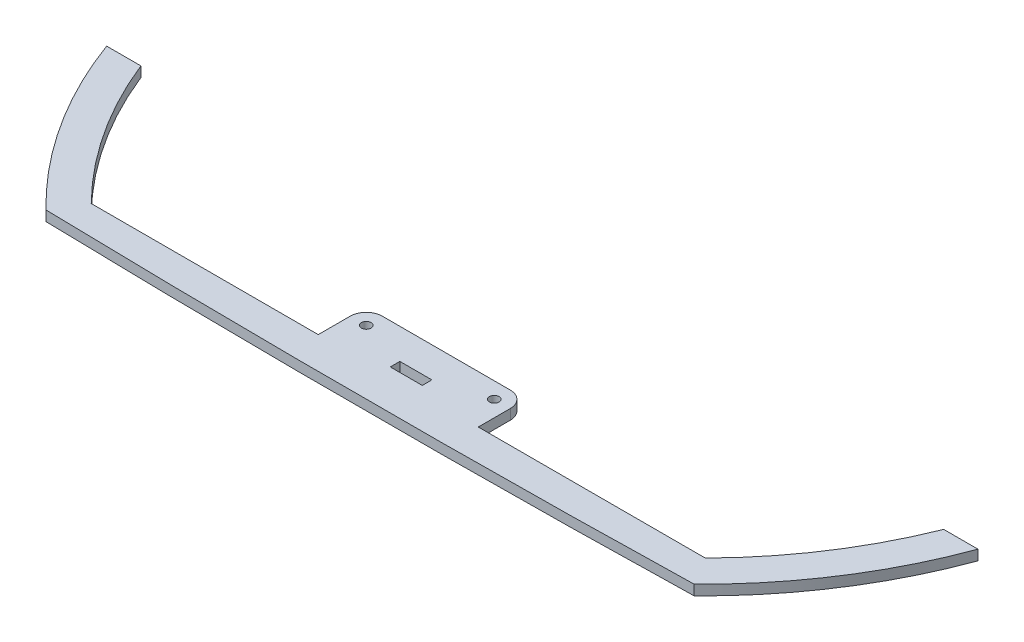
from build123d import *

# Parameters (mm, degrees)
SKETCH_1_R      = 1.5
SKETCH_1_W      = 10
SKETCH_1_H      = 3
EXTRUDE_1_DEPTH = 3.175


with BuildPart() as part:
    # 草图1 → 凸台-拉伸1 (new body)
    with BuildSketch(Plane(origin=(0, 0, 0), x_dir=(1, 0, 0), z_dir=(0, 1, 0))):
        with BuildLine():
            Line((-25, -10), (-95.916630466, -10))
            ThreePointArc((-95.916630466, -10), (-112.922283606, 11.016502751), (-125.39936204, 35))
            Line((-125.39936204, 35), (-136.106575888, 35))
            ThreePointArc((-136.106575888, 35), (-121.687593109, 6.15122269), (-101.248422592, -18.796709594))
            add(Edge.make_bspline(
                [(-101.248422592, -18.796709594), (0, -21.367886927), (101.248422592, -18.796709594)],
                knots=[1.075169889, 1.075169889, 1.075169889, 2.066422765, 2.066422765, 2.066422765], degree=2, weights=[1, 0.879670959, 1]))
            ThreePointArc((101.248422592, -18.796709594), (121.687593109, 6.15122269), (136.106575888, 35))
            Line((136.106575888, 35), (125.39936204, 35))
            ThreePointArc((125.39936204, 35), (112.922283606, 11.016502751), (95.916630466, -10))
            Line((95.916630466, -10), (25, -10))
            Line((25, -10), (25, 0))
            ThreePointArc((25, 0), (23.535533906, 3.535533906), (20, 5))
            Line((20, 5), (-20, 5))
            ThreePointArc((-20, 5), (-23.535533906, 3.535533906), (-25, 0))
            Line((-25, 0), (-25, -10))
        make_face()
        with Locations((-20, 0)):
            Circle(SKETCH_1_R, mode=Mode.SUBTRACT)
        with Locations((20, 0)):
            Circle(SKETCH_1_R, mode=Mode.SUBTRACT)
        with Locations((0, -6)):
            Rectangle(SKETCH_1_W, SKETCH_1_H, mode=Mode.SUBTRACT)
    extrude(amount=EXTRUDE_1_DEPTH)


solid = part.part
